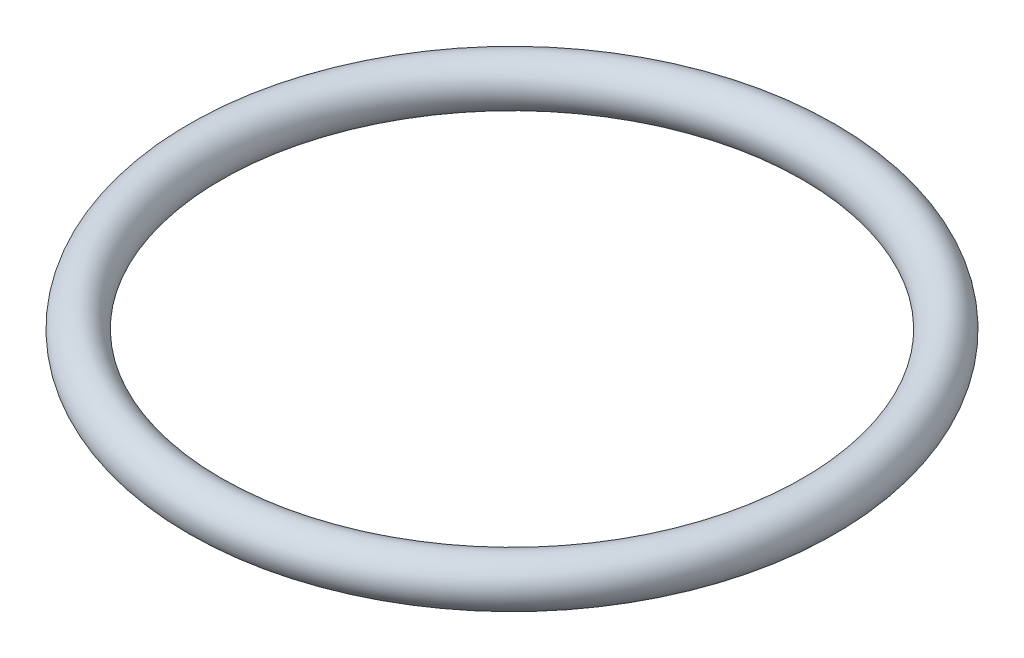
from build123d import *

# Parameters (mm, degrees)
SKETCH2_R = 1.7653


with BuildPart() as part:
    # Sweep1: sweep along a path in Sketch1
    with BuildLine(Plane(origin=(0, 0, 0), x_dir=(1, 0, 0), z_dir=(0, 1, 0))) as sweep1_path:
        CenterArc((0, 0), 22.0218, 0, 360)
    # Sketch2 → Sweep1 (sweep)
    with BuildSketch(Plane.XY):
        with Locations((-23.7871, 0)):
            Circle(SKETCH2_R)
    sweep(path=sweep1_path.line)


solid = part.part
